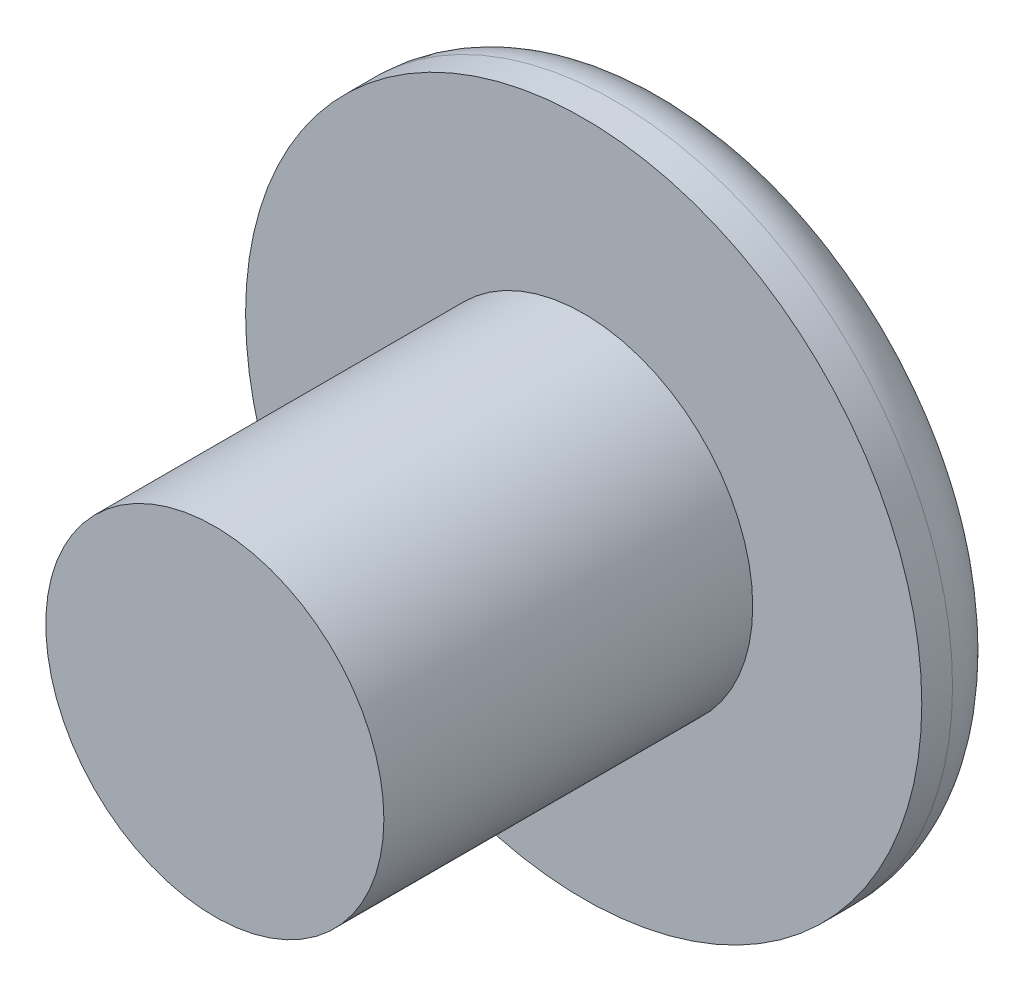
from build123d import *

# Parameters (mm, degrees)
SKETCH1_R           = 11
BOSS_EXTRUDE1_DEPTH = 3
SKETCH2_R           = 5.5
BOSS_EXTRUDE2_DEPTH = 12
FILLET1_R           = 2


with BuildPart() as part:
    # Sketch1 → Boss-Extrude1 (new body)
    with BuildSketch(Plane.XY):
        Circle(SKETCH1_R)
    extrude(amount=BOSS_EXTRUDE1_DEPTH)

    # Sketch2 → Boss-Extrude2 (add)
    with BuildSketch(Plane.XY.offset(3)):
        Circle(SKETCH2_R)
    extrude(amount=BOSS_EXTRUDE2_DEPTH)

    # Fillet1
    fillet1_edges = [part.edges().sort_by_distance(p)[0] for p in [
        (-11, 0, 0),
    ]]
    fillet(fillet1_edges, radius=FILLET1_R)


solid = part.part
